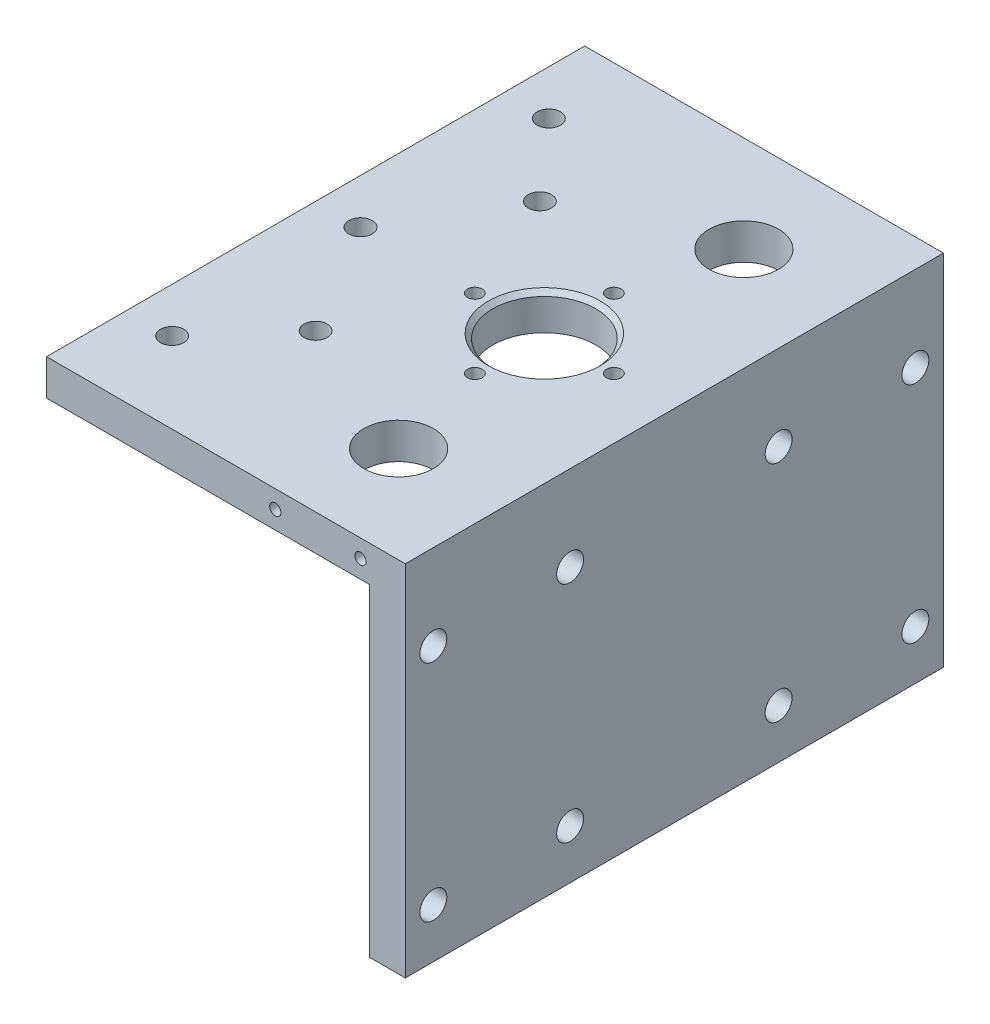
from build123d import *

# Parameters (mm, degrees)
ESTRUSIONE_ESTRUSIONE1_DEPTH = 120
TAGLIO_ESTRUSIONE2_REACH     = 82
SCHIZZO6_R                   = 7.75
TAGLIO_ESTRUSIONE3_REACH     = 82
SCHIZZO7_R                   = 11.5
M4_TAPPED_HOLE1_D            = 3.3
SCHIZZO12_R                  = 3
TAGLIO_ESTRUSIONE4_DEPTH     = 10
SCHIZZO14_R                  = 2.6
TAGLIO_ESTRUSIONE5_DEPTH     = 10
SMUSSO2_SIZE                 = 1
FORO_FILETTATO_M3_1_D        = 2.5
FORO_FILETTATO_M3_1_DEPTH    = 10
FORO_FILETTATO_M3_1_TIP      = 0.751075774


with BuildPart() as part:
    # Schizzo1 → Estrusione-Estrusione1 (new body)
    with BuildSketch(Plane.XY):
        Polygon((0, 0), (-80, 0), (-80, -8), (-8, -8), (-8, -80), (0, -80), align=None)
    extrude(amount=ESTRUSIONE_ESTRUSIONE1_DEPTH)

    # Schizzo6 → Taglio-Estrusione2 (cut, up to next)
    with BuildSketch(Plane(origin=(0, 0, 0), x_dir=(1, 0, 0), z_dir=(0, 1, 0)), mode=Mode.PRIVATE) as taglio_estrusione2_sk1:
        with Locations((-23, -21.5)):
            Circle(SCHIZZO6_R)
    taglio_estrusione2_tool1 = extrude(taglio_estrusione2_sk1.sketch, amount=-TAGLIO_ESTRUSIONE2_REACH, mode=Mode.PRIVATE) & part.part
    add(taglio_estrusione2_tool1.solids().sort_by_distance((-23, 0, 21.5))[0], mode=Mode.SUBTRACT)
    # Schizzo6 → Taglio-Estrusione2 (cut, up to next)
    with BuildSketch(Plane(origin=(0, 0, 0), x_dir=(1, 0, 0), z_dir=(0, 1, 0)), mode=Mode.PRIVATE) as taglio_estrusione2_sk2:
        with Locations((-23, -98.5)):
            Circle(SCHIZZO6_R)
    taglio_estrusione2_tool2 = extrude(taglio_estrusione2_sk2.sketch, amount=-TAGLIO_ESTRUSIONE2_REACH, mode=Mode.PRIVATE) & part.part
    add(taglio_estrusione2_tool2.solids().sort_by_distance((-23, 0, 98.5))[0], mode=Mode.SUBTRACT)

    # Schizzo7 → Taglio-Estrusione3 (cut, up to next)
    with BuildSketch(Plane(origin=(0, 0, 0), x_dir=(1, 0, 0), z_dir=(0, 1, 0)), mode=Mode.PRIVATE) as taglio_estrusione3_sk1:
        with Locations((-29, -60)):
            Circle(SCHIZZO7_R)
    taglio_estrusione3_tool1 = extrude(taglio_estrusione3_sk1.sketch, amount=-TAGLIO_ESTRUSIONE3_REACH, mode=Mode.PRIVATE) & part.part
    add(taglio_estrusione3_tool1.solids().sort_by_distance((-29, 0, 60))[0], mode=Mode.SUBTRACT)

    # M4 Tapped Hole1 (through all)
    with Locations(Plane(origin=(0, 0, 0), x_dir=(1, 0, 0), z_dir=(0, 1, 0))):
        with Locations((-29, -44.5), (-44.5, -60), (-29, -75.5), (-13.5, -60), (-29, -60)):
            Hole(M4_TAPPED_HOLE1_D / 2)

    # Schizzo12 → Taglio-Estrusione4 (cut)
    with BuildSketch(Plane(origin=(0, 0, 0), x_dir=(0, 0, -1), z_dir=(1, 0, 0))):
        with Locations((-113.75, -19)):
            Circle(SCHIZZO12_R)
        with Locations((-83.25, -19)):
            Circle(SCHIZZO12_R)
        with Locations((-36.75, -19)):
            Circle(SCHIZZO12_R)
        with Locations((-6.25, -19)):
            Circle(SCHIZZO12_R)
        with Locations((-83.25, -69)):
            Circle(SCHIZZO12_R)
        with Locations((-113.75, -69)):
            Circle(SCHIZZO12_R)
        with Locations((-6.25, -69)):
            Circle(SCHIZZO12_R)
        with Locations((-36.75, -69)):
            Circle(SCHIZZO12_R)
    extrude(amount=-TAGLIO_ESTRUSIONE4_DEPTH, mode=Mode.SUBTRACT)

    # Schizzo14 → Taglio-Estrusione5 (cut)
    with BuildSketch(Plane(origin=(0, 0, 0), x_dir=(1, 0, 0), z_dir=(0, 1, 0))):
        with Locations((-70, -18)):
            Circle(SCHIZZO14_R)
        with Locations((-70, -60)):
            Circle(SCHIZZO14_R)
        with Locations((-70, -102)):
            Circle(SCHIZZO14_R)
        with Locations((-55, -35)):
            Circle(SCHIZZO14_R)
        with Locations((-55, -85)):
            Circle(SCHIZZO14_R)
    extrude(amount=-TAGLIO_ESTRUSIONE5_DEPTH, mode=Mode.SUBTRACT)

    # Smusso2
    smusso2_edges = [part.edges().sort_by_distance(p)[0] for p in [
        (-40.5, 0, 60),
    ]]
    chamfer(smusso2_edges, length=SMUSSO2_SIZE)

    # Foro filettato M3-1
    with Locations(Plane.XY.offset(120)):
        with Locations((-10, -4), (-29, -4)):
            Hole(FORO_FILETTATO_M3_1_D / 2, depth=FORO_FILETTATO_M3_1_DEPTH)
            with Locations((0, 0, -(FORO_FILETTATO_M3_1_DEPTH + FORO_FILETTATO_M3_1_TIP / 2))):  # 118° drill point
                Cone(0, FORO_FILETTATO_M3_1_D / 2, FORO_FILETTATO_M3_1_TIP, mode=Mode.SUBTRACT)


solid = part.part
